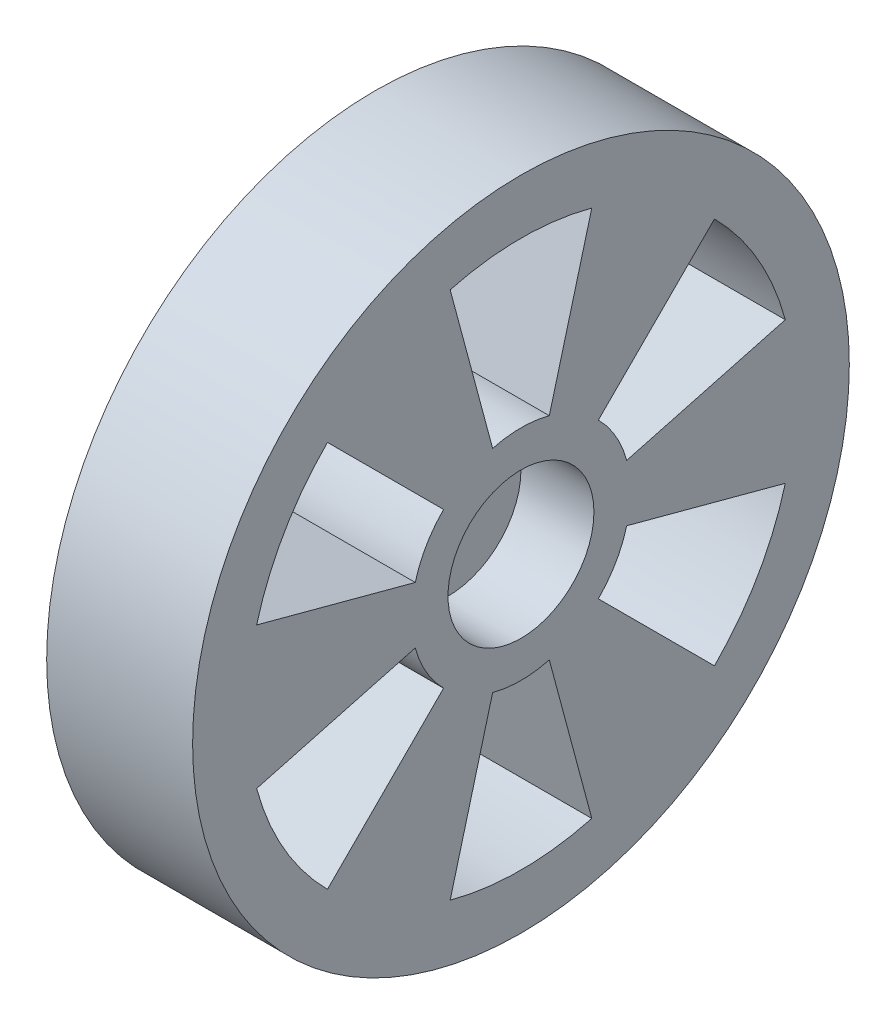
from build123d import *

# Parameters (mm, degrees)
SKETCH_1_R          = 10
EXTRUDE_1_DEPTH     = 20
SKETCH_2_R          = 45
EXTRUDE_2_DEPTH     = 20
CUT_EXTRUDE_1_DEPTH = 20
SKETCH_4_R          = 10
CUT_EXTRUDE_2_DEPTH = 10


with BuildPart() as part:
    # 草图1 → 凸台-拉伸1 (new body)
    with BuildSketch(Plane(origin=(0, 0, 0), x_dir=(0, 0, -1), z_dir=(1, 0, 0))):
        Circle(SKETCH_1_R)
    extrude(amount=EXTRUDE_1_DEPTH)

    # 草图2 → 凸台-拉伸2 (add)
    with BuildSketch(Plane(origin=(20, 0, 0), x_dir=(0, 0, -1), z_dir=(1, 0, 0))):
        Circle(SKETCH_2_R)
    extrude(amount=EXTRUDE_2_DEPTH)

    # 草图3 → 切除-拉伸1 (cut)
    with BuildSketch(Plane.ZY.offset(-20)):
        with BuildLine():
            Line((-9.705714191, 36.222218486), (-3.882285677, 14.488887394))
            ThreePointArc((-3.882285677, 14.488887394), (0, 15), (3.882285677, 14.488887394))
            Line((3.882285677, 14.488887394), (9.705714191, 36.222218486))
            ThreePointArc((9.705714191, 36.222218486), (0, 37.5), (-9.705714191, 36.222218486))
        make_face()
        with BuildLine():
            Line((26.516504294, 26.516504294), (10.606601718, 10.606601718))
            ThreePointArc((10.606601718, 10.606601718), (12.990381057, 7.5), (14.488887394, 3.882285677))
            Line((14.488887394, 3.882285677), (36.222218486, 9.705714191))
            ThreePointArc((36.222218486, 9.705714191), (32.475952642, 18.75), (26.516504294, 26.516504294))
        make_face()
        with BuildLine():
            Line((36.222218486, -9.705714191), (14.488887394, -3.882285677))
            ThreePointArc((14.488887394, -3.882285677), (12.990381057, -7.5), (10.606601718, -10.606601718))
            Line((10.606601718, -10.606601718), (26.516504294, -26.516504294))
            ThreePointArc((26.516504294, -26.516504294), (32.475952642, -18.75), (36.222218486, -9.705714191))
        make_face()
        with BuildLine():
            Line((9.705714191, -36.222218486), (3.882285677, -14.488887394))
            ThreePointArc((3.882285677, -14.488887394), (0, -15), (-3.882285677, -14.488887394))
            Line((-3.882285677, -14.488887394), (-9.705714191, -36.222218486))
            ThreePointArc((-9.705714191, -36.222218486), (0, -37.5), (9.705714191, -36.222218486))
        make_face()
        with BuildLine():
            Line((-26.516504294, -26.516504294), (-10.606601718, -10.606601718))
            ThreePointArc((-10.606601718, -10.606601718), (-12.990381057, -7.5), (-14.488887394, -3.882285677))
            Line((-14.488887394, -3.882285677), (-36.222218486, -9.705714191))
            ThreePointArc((-36.222218486, -9.705714191), (-32.475952642, -18.75), (-26.516504294, -26.516504294))
        make_face()
        with BuildLine():
            Line((-36.222218486, 9.705714191), (-14.488887394, 3.882285677))
            ThreePointArc((-14.488887394, 3.882285677), (-12.990381057, 7.5), (-10.606601718, 10.606601718))
            Line((-10.606601718, 10.606601718), (-26.516504294, 26.516504294))
            ThreePointArc((-26.516504294, 26.516504294), (-32.475952642, 18.75), (-36.222218486, 9.705714191))
        make_face()
    extrude(amount=-CUT_EXTRUDE_1_DEPTH, mode=Mode.SUBTRACT)

    # 草图4 → 切除-拉伸2 (cut)
    with BuildSketch(Plane(origin=(40, 0, 0), x_dir=(0, 0, -1), z_dir=(1, 0, 0))):
        Circle(SKETCH_4_R)
    extrude(amount=-CUT_EXTRUDE_2_DEPTH, mode=Mode.SUBTRACT)


solid = part.part
